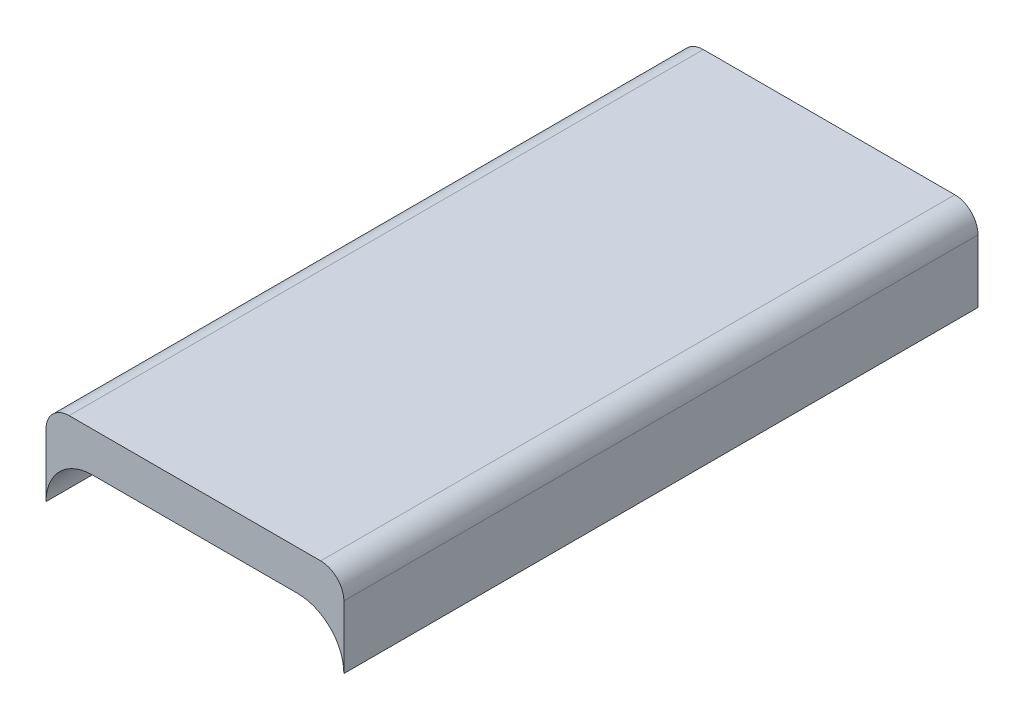
from build123d import *

# Parameters (mm, degrees)
SKETCH1_W           = 45
SKETCH1_H           = 95.8
BOSS_EXTRUDE1_DEPTH = 13
CUT_EXTRUDE1_DEPTH  = 96.8
FILLET2_R           = 3.5


with BuildPart() as part:
    # Sketch1 → Boss-Extrude1 (new body)
    with BuildSketch(Plane(origin=(0, 0, 0), x_dir=(1, 0, 0), z_dir=(0, 1, 0))):
        Rectangle(SKETCH1_W, SKETCH1_H)
    extrude(amount=BOSS_EXTRUDE1_DEPTH)

    # Sketch15 → Cut-Extrude1 (cut, through all)
    with BuildSketch(Plane.XY.offset(47.9)):
        with BuildLine():
            Line((-15.5, 7), (15.5, 7))
            ThreePointArc((15.5, 7), (20.449747468, 4.949747468), (22.5, 0))
            Line((22.5, 0), (-22.5, 0))
            ThreePointArc((-22.5, 0), (-20.449747468, 4.949747468), (-15.5, 7))
        make_face()
    extrude(amount=-CUT_EXTRUDE1_DEPTH, mode=Mode.SUBTRACT)

    # Fillet2
    fillet2_edges = [part.edges().sort_by_distance(p)[0] for p in [
        (22.5, 13, 0),
        (-22.5, 13, 0),
    ]]
    fillet(fillet2_edges, radius=FILLET2_R)


solid = part.part
